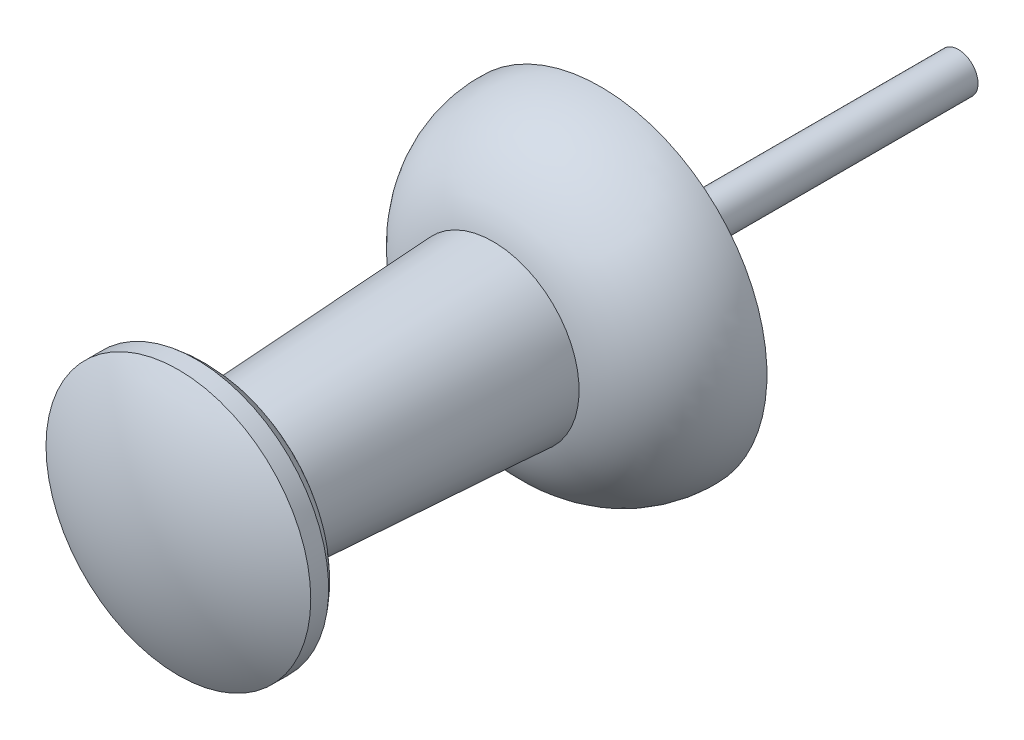
from build123d import *


with BuildPart() as part:
    # Sketch2 → Revolve1 (revolve)
    with BuildSketch(Plane(origin=(0, 0, 0), x_dir=(0, 0, -1), z_dir=(1, 0, 0))):
        with BuildLine():
            Line((10, 0.55), (0, 0.55))
            Line((0, 0.55), (0, 4.65))
            ThreePointArc((0, 4.65), (-1.89487545, 4.0515006), (-3, 2.4))
            Line((-3, 2.4), (-10.5, 2))
            ThreePointArc((-10.5, 2), (-10.687950632, 2.949787938), (-11.3, 3.7))
            Line((-11.3, 3.7), (-11.8, 3.7))
            ThreePointArc((-11.8, 3.7), (-12.545594122, 1.91637679), (-12.8, 0))
            Line((-12.8, 0), (0, 0))
            Line((0, 0), (10, 0))
            Line((10, 0), (10, 0.55))
        make_face()
    revolve(axis=Axis((0, 0, -88.99), (0, 0, 1)))


solid = part.part
